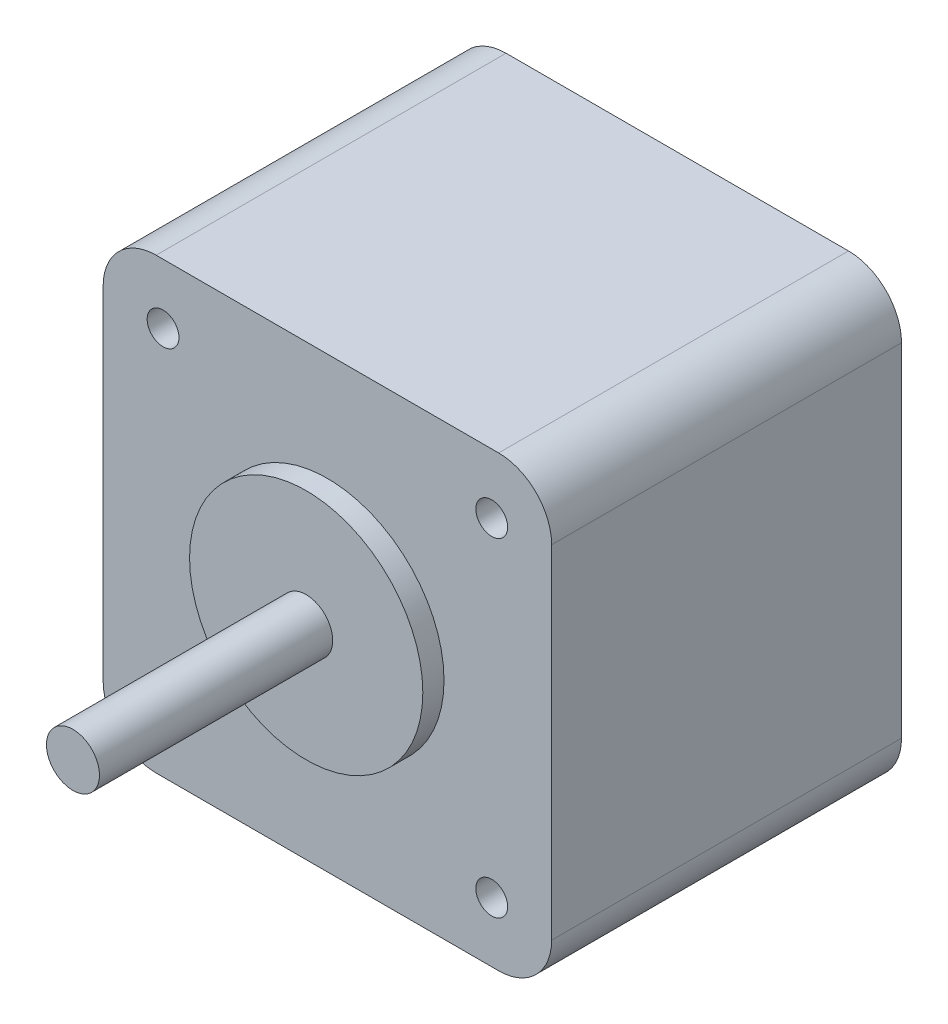
from build123d import *

# Parameters (mm, degrees)
BOSS_EXTRUDE1_DEPTH = 16.5
SKETCH5_R           = 1.5
CUT_EXTRUDE1_DEPTH  = 34
SKETCH2_R           = 2.5
BOSS_EXTRUDE2_DEPTH = 24
SKETCH3_R           = 11
BOSS_EXTRUDE3_DEPTH = 2


with BuildPart() as part:
    # Sketch1 → Boss-Extrude1 (new body, symmetric)
    with BuildSketch(Plane.XY):
        with BuildLine():
            Line((-16.15, -21.15), (16.15, -21.15))
            ThreePointArc((16.15, -21.15), (19.685533906, -19.685533906), (21.15, -16.15))
            Line((21.15, -16.15), (21.15, 16.15))
            ThreePointArc((21.15, 16.15), (19.685533906, 19.685533906), (16.15, 21.15))
            Line((16.15, 21.15), (-16.15, 21.15))
            ThreePointArc((-16.15, 21.15), (-19.685533906, 19.685533906), (-21.15, 16.15))
            Line((-21.15, 16.15), (-21.15, -16.15))
            ThreePointArc((-21.15, -16.15), (-19.685533906, -19.685533906), (-16.15, -21.15))
        make_face()
    extrude(amount=BOSS_EXTRUDE1_DEPTH, both=True)

    # Sketch5 → Cut-Extrude1 (cut, through all)
    with BuildSketch(Plane.XY.offset(16.5)):
        with Locations((-15.5, 15.5)):
            Circle(SKETCH5_R)
        with Locations((15.5, 15.5)):
            Circle(SKETCH5_R)
        with Locations((15.5, -15.5)):
            Circle(SKETCH5_R)
        with Locations((-15.5, -15.5)):
            Circle(SKETCH5_R)
    extrude(amount=-CUT_EXTRUDE1_DEPTH, mode=Mode.SUBTRACT)

    # Sketch2 → Boss-Extrude2 (add)
    with BuildSketch(Plane.XY.offset(16.5)):
        Circle(SKETCH2_R)
    extrude(amount=BOSS_EXTRUDE2_DEPTH)

    # Sketch3 → Boss-Extrude3 (add)
    with BuildSketch(Plane.XY.offset(16.5)):
        Circle(SKETCH3_R)
    extrude(amount=BOSS_EXTRUDE3_DEPTH)


solid = part.part
